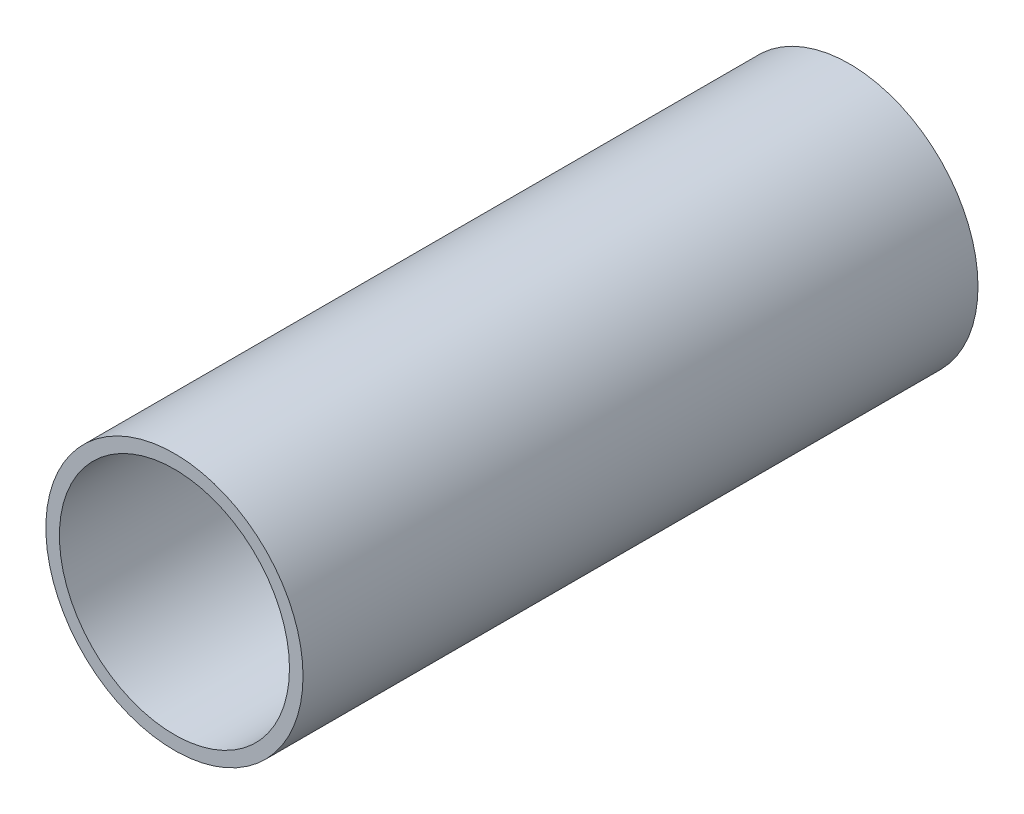
from build123d import *

# Parameters (mm, degrees)
SKETCH1_R           = 57.15
SKETCH1_R_2         = 51.1302
EXTRUDE_THIN1_DEPTH = 150


with BuildPart() as part:
    # Sketch1 → Extrude-Thin1 (new body, symmetric)
    with BuildSketch(Plane.XY):
        Circle(SKETCH1_R)
        Circle(SKETCH1_R_2, mode=Mode.SUBTRACT)
    extrude(amount=EXTRUDE_THIN1_DEPTH, both=True)


solid = part.part
